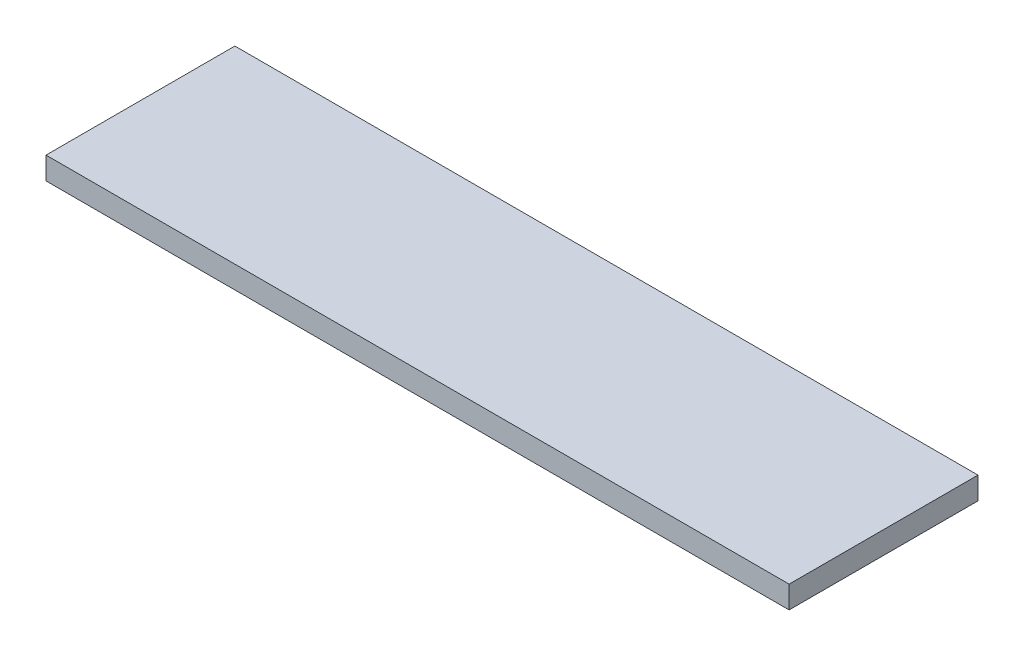
from build123d import *

# Parameters (mm, degrees)
SKETCH_1_W      = 598
SKETCH_1_H      = 152
EXTRUDE_1_DEPTH = 18


with BuildPart() as part:
    # Эскиз1 → Бобышка-Вытянуть1 (new body)
    with BuildSketch(Plane(origin=(0, 0, 0), x_dir=(1, 0, 0), z_dir=(0, 1, 0))):
        Rectangle(SKETCH_1_W, SKETCH_1_H)
    extrude(amount=EXTRUDE_1_DEPTH)


solid = part.part
